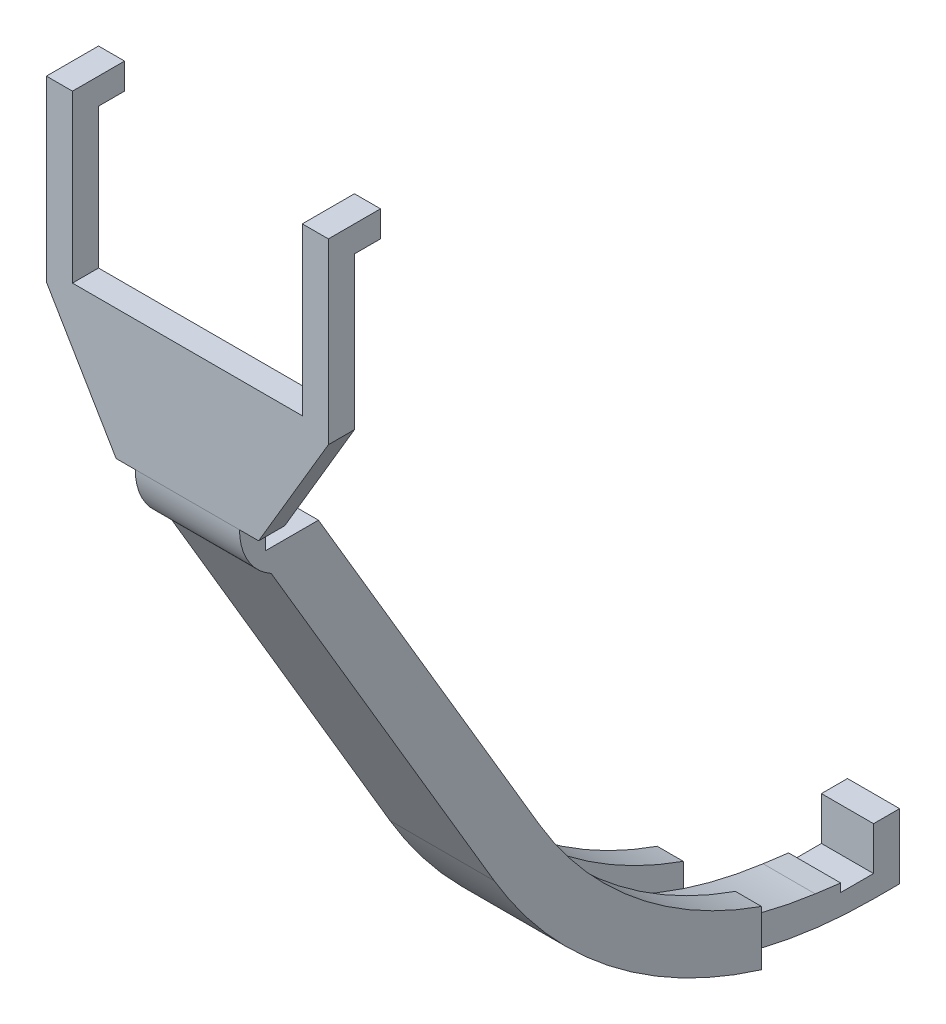
from build123d import *

# Parameters (mm, degrees)
SKETCH5_W           = 12.880016042
SKETCH5_H           = 15.834691301
CUT_EXTRUDE2_DEPTH  = 7.62
CUT_EXTRUDE6_REACH  = 62
SKETCH11_W          = 3.175
SKETCH11_H          = 3.175
BOSS_EXTRUDE1_DEPTH = 6.35
CUT_EXTRUDE4_DEPTH  = 3.175
SKETCH10_W          = 4
SKETCH10_H          = 0.5
CUT_EXTRUDE5_DEPTH  = 37.349999944
CUT_EXTRUDE7_DEPTH  = 40.64
BOSS_EXTRUDE3_DEPTH = 12.7
SKETCH19_W          = 21.319602533
SKETCH19_H          = 36.10119369
CUT_EXTRUDE10_DEPTH = 13.7
SKETCH21_W          = 9.2375
SKETCH21_H          = 32.92619369
SKETCH21_H_2        = 3.175
BOSS_EXTRUDE4_DEPTH = 3.175
SKETCH15_W          = 6.35
SKETCH15_H          = 3.175
BOSS_EXTRUDE2_DEPTH = 1.5875
SKETCH17_W          = 3.175
SKETCH17_H          = 46.222237063
CUT_EXTRUDE9_DEPTH  = 20
SKETCH22_W          = 28
SKETCH22_H          = 20.25
CUT_EXTRUDE11_DEPTH = 84.59000802
SKETCH23_W          = 1.5875
SKETCH23_H          = 32.92619369
BOSS_EXTRUDE5_DEPTH = 3.175
CUT_EXTRUDE12_DEPTH = 104.974999944


with BuildPart() as part:
    # Sketch2 → Revolve1 (revolve)
    with BuildSketch(Plane(origin=(0, 0, 0), x_dir=(0, 0, -1), z_dir=(1, 0, 0))):
        Polygon((0, -50.8), (-29.999999944, 0), (0, 0), align=None)
    revolve(axis=Axis((0, 0, 0), (0, -1, 0)))

    # Sketch4 → Cut-Revolve1 (revolve, cut)
    with BuildSketch(Plane(origin=(0, 0, 0), x_dir=(0, 0, -1), z_dir=(1, 0, 0))):
        Polygon((0, -45.72), (-24.919999944, 0), (0, 0), align=None)
    revolve(axis=Axis((0, 16.11457811, 0), (0, -1, 0)), mode=Mode.SUBTRACT)

    # Sketch5 → Cut-Extrude2 (cut, symmetric)
    with BuildSketch(Plane(origin=(0, 0, 0), x_dir=(0, 0, -1), z_dir=(1, 0, 0))):
        with Locations((0, -47.812265381)):
            Rectangle(SKETCH5_W, SKETCH5_H)
    extrude(amount=CUT_EXTRUDE2_DEPTH, both=True, mode=Mode.SUBTRACT)

    # Sketch11 → Cut-Extrude6 (cut, up to next)
    with BuildSketch(Plane.XY.offset(29.999999944), mode=Mode.PRIVATE) as cut_extrude6_sk1:
        with Locations((4.7625, -1.5875)):
            Rectangle(SKETCH11_W, SKETCH11_H)
    cut_extrude6_tool1 = extrude(cut_extrude6_sk1.sketch, amount=-CUT_EXTRUDE6_REACH, mode=Mode.PRIVATE) & part.part
    add(cut_extrude6_tool1.solids().sort_by_distance((4.7625, -1.5875, 30))[0], mode=Mode.SUBTRACT)
    # Sketch11 → Cut-Extrude6 (cut, up to next)
    with BuildSketch(Plane.XY.offset(29.999999944), mode=Mode.PRIVATE) as cut_extrude6_sk2:
        with Locations((-4.7625, -1.5875)):
            Rectangle(SKETCH11_W, SKETCH11_H)
    cut_extrude6_tool2 = extrude(cut_extrude6_sk2.sketch, amount=-CUT_EXTRUDE6_REACH, mode=Mode.PRIVATE) & part.part
    add(cut_extrude6_tool2.solids().sort_by_distance((-4.7625, -1.5875, 30))[0], mode=Mode.SUBTRACT)

    # Sketch6 → Boss-Extrude1 (add, symmetric)
    with BuildSketch(Plane(origin=(0, 0, 0), x_dir=(0, 0, -1), z_dir=(1, 0, 0))):
        with BuildLine():
            Line((0, -39.89491973), (-7.374618631, -39.89491973))
            Line((-7.374618631, -39.89491973), (21.419811292, -88.653487823))
            ThreePointArc((21.419811292, -88.653487823), (33.996187642, -103.472377364), (50.8, -113.239496671))
            ThreePointArc((50.8, -113.239496671), (60.639246777, -115.932696949), (70.8, -116.84))
            Line((70.8, -116.84), (73.975, -116.84))
            Line((73.975, -116.84), (73.975, -108.9025))
            Line((73.975, -108.9025), (70.8, -108.9025))
            Line((70.8, -108.9025), (70.8, -110.49))
            ThreePointArc((70.8, -110.49), (45.518672683, -103.782529931), (26.887551662, -85.424507296))
            Line((26.887551662, -85.424507296), (0, -39.89491973))
        make_face()
        Polygon((-30.934610553, 0), (-7.374618631, -39.89491973), (0, -39.89491973), (-23.559991923, 0), align=None)
    extrude(amount=BOSS_EXTRUDE1_DEPTH, both=True)

    # Sketch7 → Cut-Extrude4 (cut)
    with BuildSketch(Plane(origin=(0, 0, 0), x_dir=(0, 0, -1), z_dir=(1, 0, 0))):
        with BuildLine():
            Line((-3.175, -39.89491973), (24.533521366, -86.814682665))
            ThreePointArc((24.533521366, -86.814682665), (41.129063901, -104.288765008), (63.693035948, -112.75178759))
            ThreePointArc((63.693035948, -112.75178759), (67.245408265, -113.217029966), (70.8, -113.665))
            Line((70.8, -113.665), (70.8, -110.49))
            ThreePointArc((70.8, -110.49), (54.803942003, -107.916398221), (40.422357136, -100.455345061))
            ThreePointArc((40.422357136, -100.455345061), (32.902296459, -93.617671422), (26.887551662, -85.424507296))
            Line((26.887551662, -85.424507296), (-23.559991923, 0))
            Line((-23.559991923, 0), (-26.734991923, 0))
            Line((-26.734991923, 0), (-3.175, -39.89491973))
        make_face()
    cut_extrude4 = extrude(amount=-CUT_EXTRUDE4_DEPTH, mode=Mode.SUBTRACT)

    # Mirror1: Cut-Extrude4 across plane
    add(cut_extrude4.mirror(Plane(origin=(0, 0, 0), x_dir=(0, 0, 1), z_dir=(1, 0, 0))), mode=Mode.SUBTRACT)

    # Sketch9 → Cut-Revolve2 (revolve, cut)
    with BuildSketch(Plane(origin=(0, 0, 0), x_dir=(0, 0, -1), z_dir=(1, 0, 0))):
        Polygon((0, 0), (-24.9199908, 0), (-0.536470716, -39.89491973), (0, -39.89491973), align=None)
    revolve(axis=Axis((0, 16.11457811, 0), (0, -1, 0)), mode=Mode.SUBTRACT)

    # Sketch10 → Cut-Extrude5 (cut, through all)
    with BuildSketch(Plane.ZY.offset(6.35)):
        with BuildLine():
            Line((-66.8, -113.665), (-66.8, -110.332889222))
            ThreePointArc((-66.8, -110.332889222), (-68.798457857, -110.450707168), (-70.8, -110.49))
            Line((-70.8, -110.49), (-70.8, -113.665))
            Line((-70.8, -113.665), (-66.8, -113.665))
        make_face()
        with Locations((-68.8, -113.915)):
            Rectangle(SKETCH10_W, SKETCH10_H)
    extrude(amount=-CUT_EXTRUDE5_DEPTH, mode=Mode.SUBTRACT)

    # Sketch12 → Cut-Extrude7 (cut, symmetric)
    with BuildSketch(Plane.ZY):
        Polygon((30, 0), (-61.025869449, 0), (-61.025869449, -39.89491973), (-6.440008021, -39.89491973), (6.44000802, -39.89491973), (27.945214206, -3.175), align=None)
    extrude(amount=CUT_EXTRUDE7_DEPTH, both=True, mode=Mode.SUBTRACT)

    # Sketch18 → Boss-Extrude3 (add)
    with BuildSketch(Plane.ZY.offset(6.35)):
        with BuildLine():
            Line((6.44000802, -39.89491973), (6.44000802, 0))
            Line((6.44000802, 0), (9.61500802, 0))
            Line((9.61500802, 0), (9.61500802, -34.473639686))
            Line((9.61500802, -34.473639686), (9.61500802, -36.10119369))
            ThreePointArc((9.61500802, -36.10119369), (8.57844205, -39.89491973), (5.756782033, -42.634456374))
            Line((5.756782033, -42.634456374), (6.44000802, -41.477527034))
            Line((6.44000802, -41.477527034), (6.44000802, -39.89491973))
        make_face()
    extrude(amount=-BOSS_EXTRUDE3_DEPTH)

    # Sketch19 → Cut-Extrude10 (cut, through all)
    with BuildSketch(Plane.ZY.offset(6.35)):
        with Locations((20.274809287, -18.050596845)):
            Rectangle(SKETCH19_W, SKETCH19_H)
    extrude(amount=-CUT_EXTRUDE10_DEPTH, mode=Mode.SUBTRACT)

    # Sketch21 → Boss-Extrude4 (add)
    with BuildSketch(Plane.XY.offset(9.61500802)):
        with Locations((-10.96875, -19.638096845)):
            Rectangle(SKETCH21_W, SKETCH21_H)
        with Locations((10.96875, -19.638096845)):
            Rectangle(SKETCH21_W, SKETCH21_H)
        with Locations((10.96875, -1.5875)):
            Rectangle(SKETCH21_W, SKETCH21_H_2)
        with Locations((-10.96875, -1.5875)):
            Rectangle(SKETCH21_W, SKETCH21_H_2)
    extrude(amount=-BOSS_EXTRUDE4_DEPTH)

    # Sketch15 → Boss-Extrude2 (add, symmetric)
    with BuildSketch(Plane.ZY.offset(15.5875)):
        with Locations((6.44000802, -1.5875)):
            Rectangle(SKETCH15_W, SKETCH15_H)
    boss_extrude2 = extrude(amount=BOSS_EXTRUDE2_DEPTH, both=True)

    # Mirror2: Boss-Extrude2 across plane
    add(boss_extrude2.mirror(Plane(origin=(0, 0, 0), x_dir=(0, 0, 1), z_dir=(1, 0, 0))))

    # Sketch17 → Cut-Extrude9 (cut)
    with BuildSketch(Plane(origin=(0, 0, -73.975), x_dir=(-1, 0, 0), z_dir=(0, 0, -1))):
        with Locations((-4.7625, -93.728881469)):
            Rectangle(SKETCH17_W, SKETCH17_H)
        with Locations((4.7625, -93.728881469)):
            Rectangle(SKETCH17_W, SKETCH17_H)
    extrude(amount=-CUT_EXTRUDE9_DEPTH, mode=Mode.SUBTRACT)

    # Sketch22 → Cut-Extrude11 (cut, through all)
    with BuildSketch(Plane.XY.offset(9.61500802)):
        with Locations((0, -10.125)):
            Rectangle(SKETCH22_W, SKETCH22_H)
    extrude(amount=-CUT_EXTRUDE11_DEPTH, mode=Mode.SUBTRACT)

    # Sketch23 → Boss-Extrude5 (add)
    with BuildSketch(Plane.XY.offset(9.61500802)):
        with Locations((-16.38125, -19.638096845)):
            Rectangle(SKETCH23_W, SKETCH23_H)
        with Locations((16.38125, -19.638096845)):
            Rectangle(SKETCH23_W, SKETCH23_H)
    extrude(amount=-BOSS_EXTRUDE5_DEPTH)

    # Sketch24 → Cut-Extrude12 (cut, through all)
    with BuildSketch(Plane.XY.offset(29.999999944)):
        Polygon((-17.175, -36.10119369), (-8.68039741, -36.10119369), (-17.175, -21.71699995), align=None)
        Polygon((17.175, -21.71699995), (17.175, -36.10119369), (8.68039741, -36.10119369), align=None)
    extrude(amount=-CUT_EXTRUDE12_DEPTH, mode=Mode.SUBTRACT)


solid = part.part
